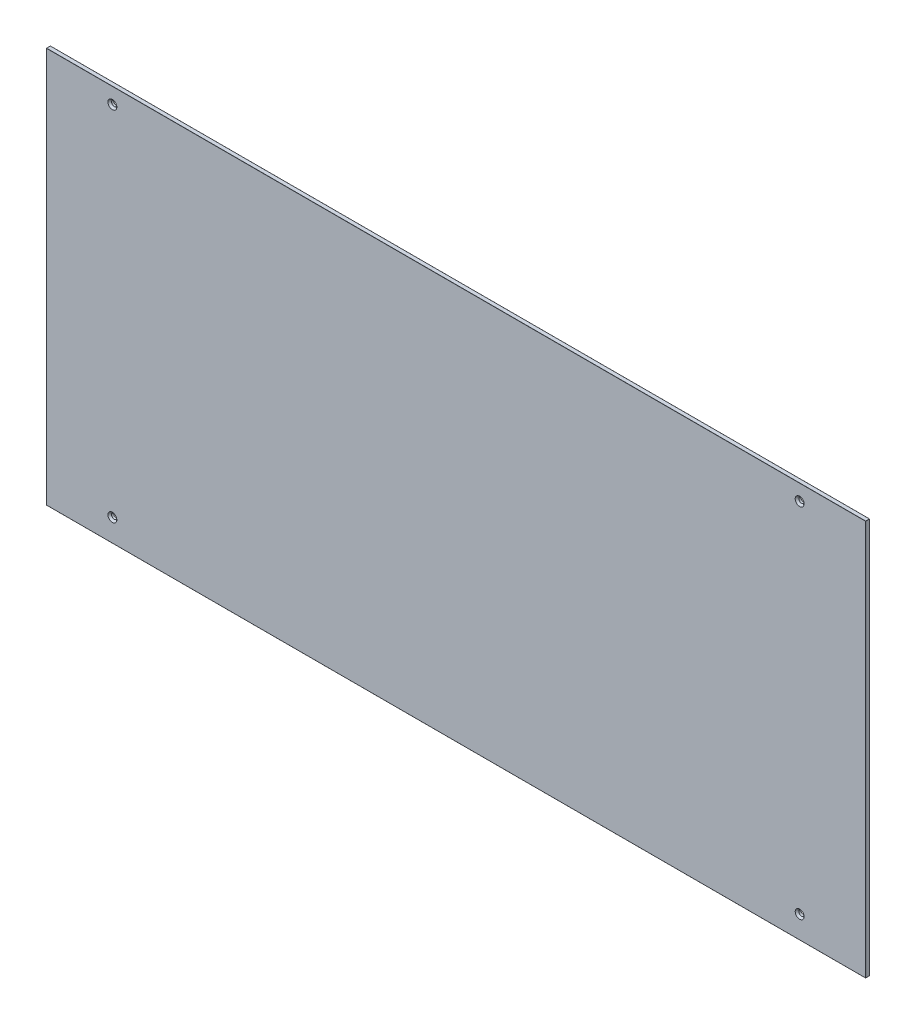
from build123d import *

# Parameters (mm, degrees)
SKETCH1_W           = 1242
SKETCH1_H           = 600
BOSS_EXTRUDE1_DEPTH = 6
SKETCH2_R           = 4
CUT_EXTRUDE1_DEPTH  = 7
CHAMFER1_SIZE       = 2.75
FILLET1_R           = 0.2


with BuildPart() as part:
    # Sketch1 → Boss-Extrude1 (new body)
    with BuildSketch(Plane.XY):
        Rectangle(SKETCH1_W, SKETCH1_H)
    extrude(amount=BOSS_EXTRUDE1_DEPTH)

    # Sketch2 → Cut-Extrude1 (cut, through all)
    with BuildSketch(Plane.XY.offset(6)):
        with Locations((-521, 276)):
            Circle(SKETCH2_R)
        with Locations((521, 276)):
            Circle(SKETCH2_R)
        with Locations((521, -266)):
            Circle(SKETCH2_R)
        with Locations((-521, -266)):
            Circle(SKETCH2_R)
    extrude(amount=-CUT_EXTRUDE1_DEPTH, mode=Mode.SUBTRACT)

    # Chamfer1
    chamfer1_edges = [part.edges().sort_by_distance(p)[0] for p in [
        (-525, 276, 6),
        (517, 276, 6),
        (517, -266, 6),
        (-525, -266, 6),
    ]]
    chamfer(chamfer1_edges, length=CHAMFER1_SIZE)

    # Fillet1
    fillet1_edges = [part.edges().sort_by_distance(p)[0] for p in [
        (-621, 0, 6),
        (0, -300, 6),
        (621, 0, 6),
        (0, -300, 0),
        (-621, 0, 0),
        (0, 300, 0),
        (621, 0, 0),
        (0, 300, 6),
        (621, -300, 3),
        (-621, -300, 3),
        (-621, 300, 3),
        (621, 300, 3),
    ]]
    fillet(fillet1_edges, radius=FILLET1_R)


solid = part.part
